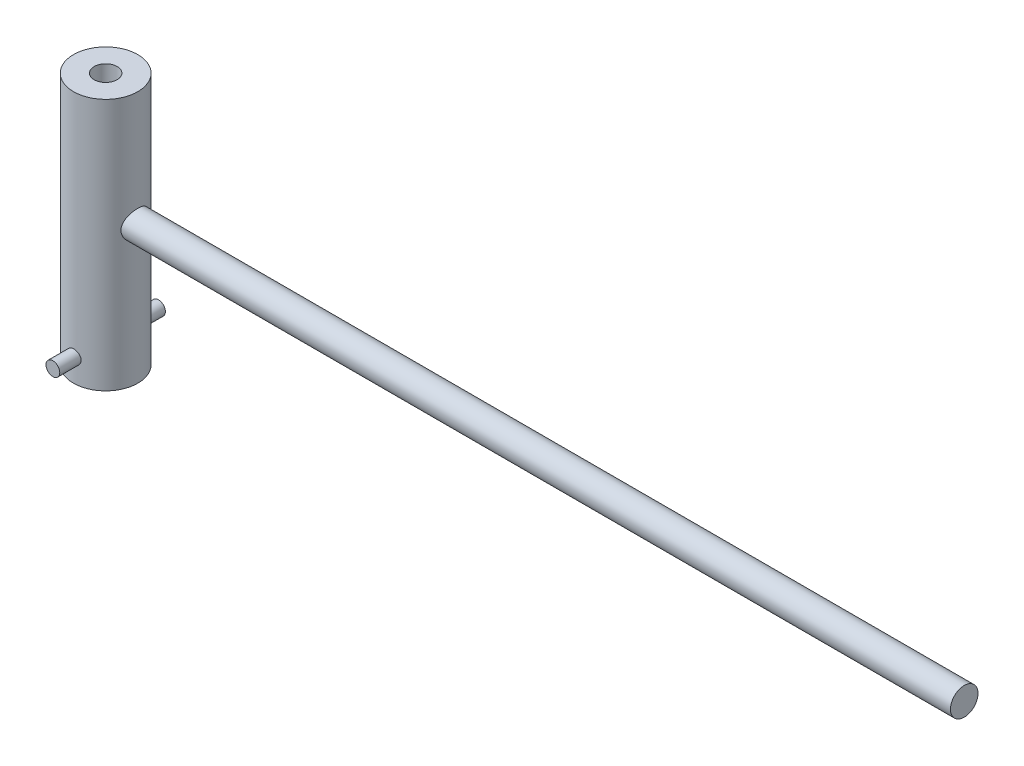
from build123d import *

# Parameters (mm, degrees)
ESQUISSE1_W             = 7
ESQUISSE1_H             = 55
ESQUISSE2_W             = 70
ESQUISSE2_H             = 3
ESQUISSE3_W             = 2
ESQUISSE3_H             = 1.5
ESQUISSE5_R             = 2.5
ENL_V_MAT_EXTRU_1_DEPTH = 96.052617065
ESQUISSE8_R             = 1.5
BOSS_EXTRU_1_DEPTH      = 2.5
BOSS_EXTRU_1_DEPTH_BACK = 3
ESQUISSE11_R            = 1.5
BOSS_EXTRU_2_DEPTH      = 2.5
BOSS_EXTRU_2_DEPTH_BACK = 3
ESQUISSE12_R            = 3
BOSS_EXTRU_3_DEPTH      = 110
BOSS_EXTRU_3_DEPTH_BACK = 71.5


with BuildPart() as part:
    # Esquisse1 → Révolution1 (revolve)
    with BuildSketch(Plane.XY, mode=Mode.PRIVATE) as r_volution1_sk:
        with Locations((3.5, -27.5)):
            Rectangle(ESQUISSE1_W, ESQUISSE1_H)
    revolve(r_volution1_sk.sketch.rotate(Axis((0, 0, 0), (0, -1, 0)), 90), axis=Axis((0, 0, 0), (0, -1, 0)))

    # Esquisse4 → Révolution5 (revolve)
    with BuildSketch(Plane(origin=(0, 0, 0), x_dir=(0, 0, -1), z_dir=(1, 0, 0)), mode=Mode.PRIVATE) as r_volution5_sk:
        Polygon((6.966968242, -50), (7, -48.5), (9, -48.5), (9, -50), align=None)
    revolve(r_volution5_sk.sketch.rotate(Axis((0, -50, 17.973106255), (0, 0, -1)), 90), axis=Axis((0, -50, 17.973106255), (0, 0, -1)))

    # Esquisse5 → Enlèv. mat.-Extru.1 (cut, through all)
    with BuildSketch(Plane(origin=(0, 0, 0), x_dir=(1, 0, 0), z_dir=(0, 1, 0))):
        with Locations(Location((0, 0, 0), (0, 0, 270))):
            Circle(ESQUISSE5_R)
    extrude(amount=-ENL_V_MAT_EXTRU_1_DEPTH, mode=Mode.SUBTRACT)



with BuildPart() as body_2:
    # Esquisse2 → Révolution2 (revolve)
    with BuildSketch(Plane.XY, mode=Mode.PRIVATE) as r_volution2_sk:
        with Locations((42, -23.5)):
            Rectangle(ESQUISSE2_W, ESQUISSE2_H)
    revolve(r_volution2_sk.sketch.rotate(Axis((-18.358665949, -25, 0), (1, 0, 0)), 90), axis=Axis((-18.358665949, -25, 0), (1, 0, 0)))


with BuildPart() as body_3:
    # Esquisse3 → Révolution4 (revolve)
    with BuildSketch(Plane(origin=(0, 0, 0), x_dir=(0, 0, -1), z_dir=(1, 0, 0)), mode=Mode.PRIVATE) as r_volution4_sk:
        with Locations((-8, -49.25)):
            Rectangle(ESQUISSE3_W, ESQUISSE3_H)
    revolve(r_volution4_sk.sketch.rotate(Axis((0, -50, 15.119555316), (0, 0, -1)), 90), axis=Axis((0, -50, 15.119555316), (0, 0, -1)))


with BuildPart() as part_1:
    add(part.part)

    add(body_3.part)  # Boss.-Extru.1 merges body 3
    # Esquisse8 → Boss.-Extru.1 (add, two sides)
    with BuildSketch(Plane.XY.offset(9)) as boss_extru_1_sk:
        with Locations((0, -50)):
            Circle(ESQUISSE8_R)
    extrude(amount=BOSS_EXTRU_1_DEPTH)
    extrude(boss_extru_1_sk.sketch, amount=-BOSS_EXTRU_1_DEPTH_BACK)

    # Esquisse11 → Boss.-Extru.2 (add, two sides)
    with BuildSketch(Plane(origin=(0, 0, -9), x_dir=(-1, 0, 0), z_dir=(0, 0, -1))) as boss_extru_2_sk:
        with Locations(Location((0, -50, 0), (0, 0, 180))):
            Circle(ESQUISSE11_R)
    extrude(amount=BOSS_EXTRU_2_DEPTH)
    extrude(boss_extru_2_sk.sketch, amount=-BOSS_EXTRU_2_DEPTH_BACK)


    add(body_2.part)  # Boss.-Extru.3 merges body 2
    # Esquisse12 → Boss.-Extru.3 (add, two sides)
    with BuildSketch(Plane(origin=(77, 0, 0), x_dir=(0, 0, -1), z_dir=(1, 0, 0))) as boss_extru_3_sk:
        with Locations(Location((0, -25, 0), (0, 0, 180))):
            Circle(ESQUISSE12_R)
    extrude(amount=BOSS_EXTRU_3_DEPTH)
    extrude(boss_extru_3_sk.sketch, amount=-BOSS_EXTRU_3_DEPTH_BACK)


solid = part_1.part
